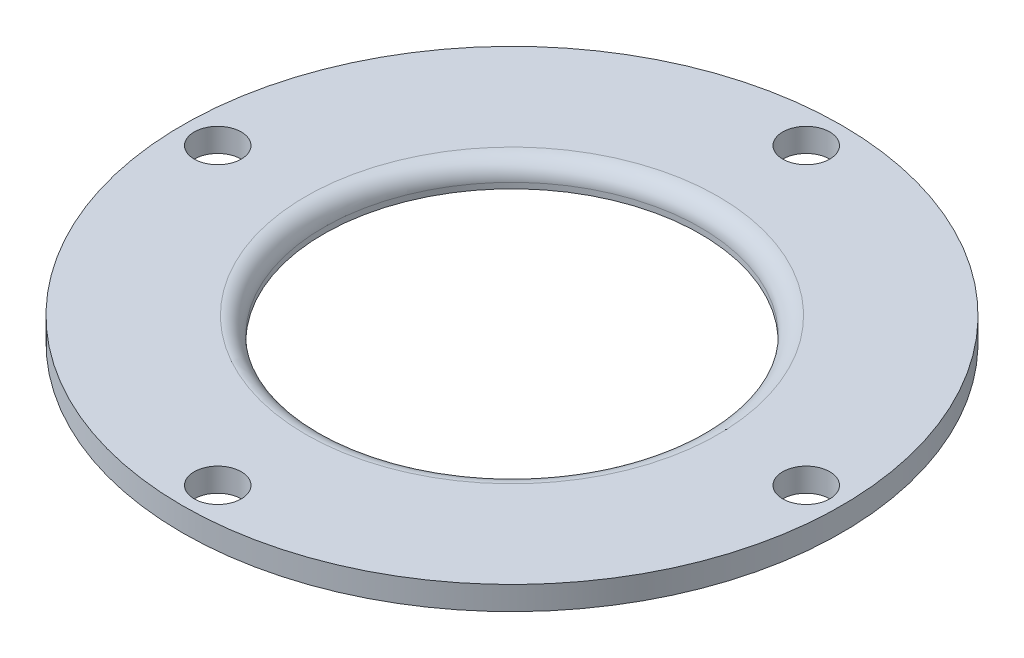
from build123d import *

# Parameters (mm, degrees)
SKETCH1_R           = 88.9
BOSS_EXTRUDE1_DEPTH = 6.35
SKETCH2_R           = 50.8
CUT_EXTRUDE1_DEPTH  = 7.35
FILLET2_R           = 4.826
SKETCH3_R           = 6.35
CUT_EXTRUDE2_DEPTH  = 7.35


with BuildPart() as part:
    # Sketch1 → Boss-Extrude1 (new body)
    with BuildSketch(Plane(origin=(0, 0, 0), x_dir=(1, 0, 0), z_dir=(0, 1, 0))):
        Circle(SKETCH1_R)
    extrude(amount=BOSS_EXTRUDE1_DEPTH)

    # Sketch2 → Cut-Extrude1 (cut, through all)
    with BuildSketch(Plane(origin=(0, 6.35, 0), x_dir=(1, 0, 0), z_dir=(0, 1, 0))):
        Circle(SKETCH2_R)
    extrude(amount=-CUT_EXTRUDE1_DEPTH, mode=Mode.SUBTRACT)

    # Fillet2
    fillet2_edges = [part.edges().sort_by_distance(p)[0] for p in [
        (-50.8, 6.35, 0),
    ]]
    fillet(fillet2_edges, radius=FILLET2_R)

    # Sketch3 → Cut-Extrude2 (cut, through all)
    with BuildSketch(Plane.XZ):
        with Locations((0, -79.375)):
            Circle(SKETCH3_R)
        with Locations((79.375, 0)):
            Circle(SKETCH3_R)
        with Locations((-79.375, 0)):
            Circle(SKETCH3_R)
        with Locations((0, 79.375)):
            Circle(SKETCH3_R)
    extrude(amount=-CUT_EXTRUDE2_DEPTH, mode=Mode.SUBTRACT)


solid = part.part
